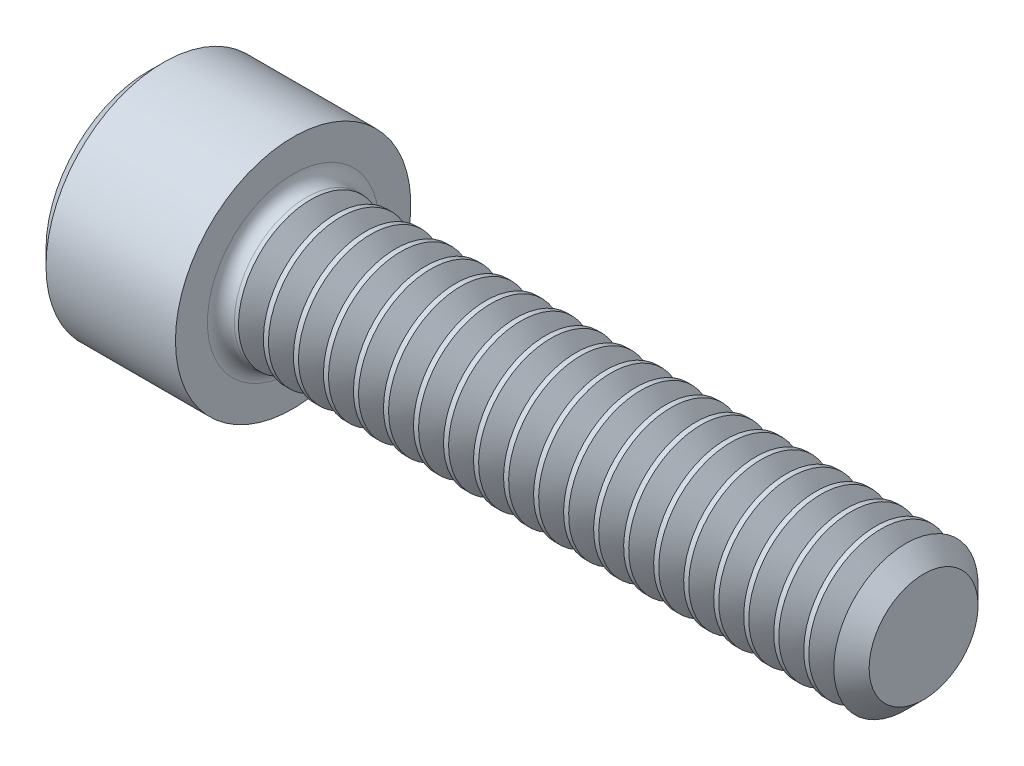
from build123d import *

# Parameters (mm, degrees)
FILLET1_R       = 0.2032
HEX_2_DEPTH     = 0.9652
THDSCHPAT_COUNT = 20
THDSCHPAT_PITCH = 0.453517


with BuildPart() as part:
    # BodySke → Base-Revolve (revolve)
    with BuildSketch(Plane.XY):
        Polygon((0, 0), (0, 1.5494), (0.2286, 1.778), (2.1844, 1.778), (2.1844, 1.0922), (11.44016, 1.0922), (11.7094, 0.82296), (11.7094, 0), align=None)
    revolve(axis=Axis((-31.75, 0, 0), (1, 0, 0)))

    # Fillet1
    fillet1_edges = [part.edges().sort_by_distance(p)[0] for p in [
        (2.1844, -1.0922, 0),
    ]]
    fillet(fillet1_edges, radius=FILLET1_R)

    # Sketch2 → Hex-PreBroach (revolve, cut)
    with BuildSketch(Plane.XY):
        Polygon((0, 0.9906), (0.9652, 0.9906), (1.537123177, 0), (0, 0), align=None)
    revolve(axis=Axis((0, 0, 0), (1, 0, 0)), mode=Mode.SUBTRACT)

    # Sketch3 → Hex 2 (cut)
    with BuildSketch(Plane(origin=(0, 0, 0), x_dir=(0, 0.5, 0.866025404), z_dir=(-1, 0, 0))):
        Polygon((0.571923177, 0.9906), (-0.571923177, 0.9906), (-1.143846353, 0), (-0.571923177, -0.9906), (0.571923177, -0.9906), (1.143846353, 0), align=None)
    extrude(amount=-HEX_2_DEPTH, mode=Mode.SUBTRACT)

    # ThdSchSke → ThreadSchematic (revolve, cut)
    with BuildSketch(Plane.XY):
        Polygon((2.63906, -0.82296), (2.450536122, -1.0922), (2.450536122, -1.36525), (2.827583878, -1.36525), (2.827583878, -1.0922), align=None)
    threadschematic = revolve(axis=Axis((-3.175, 0, 0), (1, 0, 0)), mode=Mode.SUBTRACT)

    # ThdSchPat: ThreadSchematic ×20
    with Locations(*[(i * THDSCHPAT_PITCH, 0, 0) for i in range(1, THDSCHPAT_COUNT)]):
        add(threadschematic, mode=Mode.SUBTRACT)


solid = part.part
